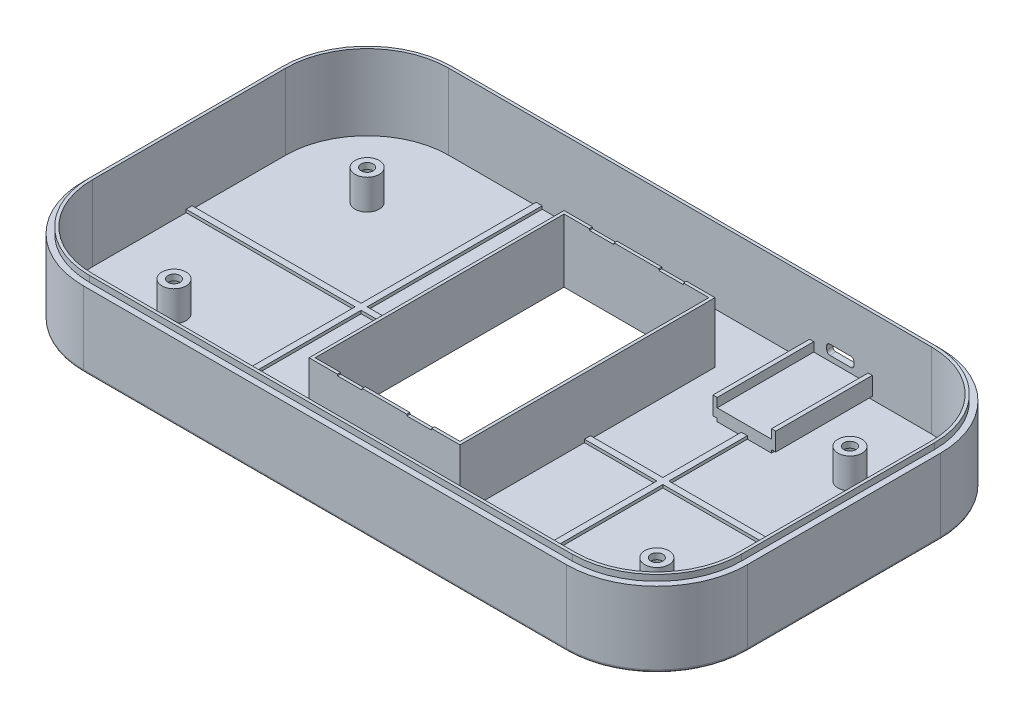
from build123d import *

# Parameters (mm, degrees)
BOSS_EXTRUDE1_DEPTH = 25
CUT_EXTRUDE1_DEPTH  = 23
BOSS_EXTRUDE2_DEPTH = 25
BOSS_EXTRUDE3_DEPTH = 2
SKETCH6_R           = 4
BOSS_EXTRUDE4_DEPTH = 10
SKETCH7_R           = 2
CUT_EXTRUDE2_DEPTH  = 54
SKETCH8_R           = 3.5
CUT_EXTRUDE3_DEPTH  = 10
BOSS_EXTRUDE5_DEPTH = 1
FILLET1_R           = 1
SKETCH11_W          = 25
SKETCH11_H          = 84.5
BOSS_EXTRUDE7_DEPTH = 22
CUT_EXTRUDE4_DEPTH  = 34.548411539
SKETCH13_W          = 8.2
SKETCH13_H          = 0.499092091
CUT_EXTRUDE5_DEPTH  = 94.548411539
SKETCH14_W          = 54
SKETCH14_H          = 88
SKETCH14_W_2        = 48
SKETCH14_H_2        = 82.5
CUT_EXTRUDE6_DEPTH  = 1
CUT_EXTRUDE7_DEPTH  = 2
SKETCH16_W          = 8
SKETCH16_H          = 6
CUT_EXTRUDE9_DEPTH  = 2
SKETCH17_W          = 18
SKETCH17_H          = 32
BOSS_EXTRUDE8_DEPTH = 4
SKETCH18_W          = 1.390332564
SKETCH18_H          = 32
BOSS_EXTRUDE9_DEPTH = 3
SKETCH19_W          = 9
SKETCH19_H          = 3.2
CUT_EXTRUDE10_DEPTH = 6
FILLET2_R           = 1
FILLET3_R           = 1
FILLET4_R           = 1
FILLET5_R           = 1
CUT_EXTRUDE12_DEPTH = 1


with BuildPart() as part:
    # Sketch1 → Boss-Extrude1 (new body)
    with BuildSketch(Plane(origin=(0, 0, 0), x_dir=(1, 0, 0), z_dir=(0, 1, 0))):
        with BuildLine():
            Line((-80, 62), (80, 62))
            ThreePointArc((80, 62), (101.213203436, 53.213203436), (110, 32))
            Line((110, 32), (110, -32))
            ThreePointArc((110, -32), (101.213203436, -53.213203436), (80, -62))
            Line((80, -62), (-80, -62))
            ThreePointArc((-80, -62), (-101.213203436, -53.213203436), (-110, -32))
            Line((-110, -32), (-110, 32))
            ThreePointArc((-110, 32), (-101.213203436, 53.213203436), (-80, 62))
        make_face()
    extrude(amount=BOSS_EXTRUDE1_DEPTH)

    # Sketch2 → Cut-Extrude1 (cut)
    with BuildSketch(Plane(origin=(0, 25, 0), x_dir=(1, 0, 0), z_dir=(0, 1, 0))):
        with BuildLine():
            Line((-80, -60), (80, -60))
            ThreePointArc((80, -60), (99.798989873, -51.798989873), (108, -32))
            Line((108, -32), (108, 32))
            ThreePointArc((108, 32), (99.798989873, 51.798989873), (80, 60))
            Line((80, 60), (-80, 60))
            ThreePointArc((-80, 60), (-99.798989873, 51.798989873), (-108, 32))
            Line((-108, 32), (-108, -32))
            ThreePointArc((-108, -32), (-99.798989873, -51.798989873), (-80, -60))
        make_face()
    extrude(amount=-CUT_EXTRUDE1_DEPTH, mode=Mode.SUBTRACT)

    # Sketch3 → Boss-Extrude2 (add)
    with BuildSketch(Plane(origin=(0, 2, 0), x_dir=(1, 0, 0), z_dir=(0, 1, 0))):
        with BuildLine():
            Line((-80, -60), (80, -60))
            ThreePointArc((80, -60), (99.798989873, -51.798989873), (108, -32))
            Line((108, -32), (108, 32))
            ThreePointArc((108, 32), (99.798989873, 51.798989873), (80, 60))
            Line((80, 60), (-80, 60))
            ThreePointArc((-80, 60), (-99.798989873, 51.798989873), (-108, 32))
            Line((-108, 32), (-108, -32))
            ThreePointArc((-108, -32), (-99.798989873, -51.798989873), (-80, -60))
        make_face()
        with BuildLine():
            Line((-80, -59), (80, -59))
            ThreePointArc((80, -59), (99.091883092, -51.091883092), (107, -32))
            Line((107, -32), (107, 32))
            ThreePointArc((107, 32), (99.091883092, 51.091883092), (80, 59))
            Line((80, 59), (-80, 59))
            ThreePointArc((-80, 59), (-99.091883092, 51.091883092), (-107, 32))
            Line((-107, 32), (-107, -32))
            ThreePointArc((-107, -32), (-99.091883092, -51.091883092), (-80, -59))
        make_face(mode=Mode.SUBTRACT)
    extrude(amount=BOSS_EXTRUDE2_DEPTH)

    # Sketch5 → Boss-Extrude3 (add)
    with BuildSketch(Plane.XZ):
        with BuildLine():
            Line((-88, 32), (-88, 20))
            Line((-88, 20), (-90, 20))
            Line((-90, 20), (-90, 32))
            ThreePointArc((-90, 32), (-87.071067812, 39.071067812), (-80, 42))
            Line((-80, 42), (-68, 42))
            Line((-68, 42), (-68, 40))
            Line((-68, 40), (-80, 40))
            ThreePointArc((-80, 40), (-85.656854249, 37.656854249), (-88, 32))
        make_face()
        with BuildLine():
            Line((-80, -40), (-68, -40))
            Line((-68, -40), (-68, -42))
            Line((-68, -42), (-80, -42))
            ThreePointArc((-80, -42), (-87.071067812, -39.071067812), (-90, -32))
            Line((-90, -32), (-90, -20))
            Line((-90, -20), (-88, -20))
            Line((-88, -20), (-88, -32))
            ThreePointArc((-88, -32), (-85.656854249, -37.656854249), (-80, -40))
        make_face()
        with BuildLine():
            Line((88, -32), (88, -20))
            Line((88, -20), (90, -20))
            Line((90, -20), (90, -32))
            ThreePointArc((90, -32), (87.071067812, -39.071067812), (80, -42))
            Line((80, -42), (68, -42))
            Line((68, -42), (68, -40))
            Line((68, -40), (80, -40))
            ThreePointArc((80, -40), (85.656854249, -37.656854249), (88, -32))
        make_face()
        with BuildLine():
            Line((80, 40), (68, 40))
            Line((68, 40), (68, 42))
            Line((68, 42), (80, 42))
            ThreePointArc((80, 42), (87.071067812, 39.071067812), (90, 32))
            Line((90, 32), (90, 20))
            Line((90, 20), (88, 20))
            Line((88, 20), (88, 32))
            ThreePointArc((88, 32), (85.656854249, 37.656854249), (80, 40))
        make_face()
    extrude(amount=BOSS_EXTRUDE3_DEPTH)

    # Sketch6 → Boss-Extrude4 (add)
    with BuildSketch(Plane(origin=(0, 2, 0), x_dir=(1, 0, 0), z_dir=(0, 1, 0))):
        with Locations((80, 32)):
            Circle(SKETCH6_R)
        with Locations((80, -32)):
            Circle(SKETCH6_R)
        with Locations((-80, -32)):
            Circle(SKETCH6_R)
        with Locations((-80, 32)):
            Circle(SKETCH6_R)
    extrude(amount=BOSS_EXTRUDE4_DEPTH)

    # Sketch7 → Cut-Extrude2 (cut)
    with BuildSketch(Plane(origin=(0, 12, 0), x_dir=(1, 0, 0), z_dir=(0, 1, 0))):
        with Locations((80, 32)):
            Circle(SKETCH7_R)
        with Locations((80, -32)):
            Circle(SKETCH7_R)
        with Locations((-80, -32)):
            Circle(SKETCH7_R)
        with Locations((-80, 32)):
            Circle(SKETCH7_R)
    extrude(amount=-CUT_EXTRUDE2_DEPTH, mode=Mode.SUBTRACT)

    # Sketch8 → Cut-Extrude3 (cut)
    with BuildSketch(Plane.XZ):
        with Locations((-80, 32)):
            Circle(SKETCH8_R)
        with Locations((-80, -32)):
            Circle(SKETCH8_R)
        with Locations((80, -32)):
            Circle(SKETCH8_R)
        with Locations((80, 32)):
            Circle(SKETCH8_R)
    extrude(amount=-CUT_EXTRUDE3_DEPTH, mode=Mode.SUBTRACT)

    # Sketch9 → Boss-Extrude5 (add)
    with BuildSketch(Plane(origin=(0, 2, 0), x_dir=(1, 0, 0), z_dir=(0, 1, 0))):
        Polygon((49, -59), (51, -59), (51, -1), (107, -1), (107, 1), (51, 1), (51, 59), (49, 59), (49, 1), (1, 1), (1, 59), (-1, 59), (-1, 1), (-49, 1), (-49, 59), (-51, 59), (-51, 1), (-107, 1), (-107, -1), (-51, -1), (-51, -59), (-49, -59), (-49, -1), (-1, -1), (-1, -59), (1, -59), (1, -1), (49, -1), align=None)
    extrude(amount=BOSS_EXTRUDE5_DEPTH)

    # Fillet1
    fillet1_edges = [part.edges().sort_by_distance(p)[0] for p in [
        (0, 0, 62),
        (-101.213203436, 0, 53.213203436),
        (-110, 0, 0),
        (-101.213203436, 0, -53.213203436),
        (0, 0, -62),
        (101.213203436, 0, -53.213203436),
        (110, 0, 0),
        (101.213203436, 0, 53.213203436),
    ]]
    fillet(fillet1_edges, radius=FILLET1_R)

    # Sketch11 → Boss-Extrude7 (add)
    with BuildSketch(Plane.XZ):
        with Locations((12.5, 0)):
            Rectangle(SKETCH11_W, SKETCH11_H)
        with Locations((-12.5, 0)):
            Rectangle(SKETCH11_W, SKETCH11_H)
    extrude(amount=-BOSS_EXTRUDE7_DEPTH)

    # Sketch12 → Cut-Extrude4 (cut)
    with BuildSketch(Plane(origin=(0, 22, 0), x_dir=(1, 0, 0), z_dir=(0, 1, 0))):
        Polygon((-24, 41.25), (-24, 40.56), (24, -40.56), (24, 41.25), align=None)
        Polygon((24, -40.56), (-24, 40.56), (-24, -41.25), (24, -41.25), align=None)
    extrude(amount=-CUT_EXTRUDE4_DEPTH, mode=Mode.SUBTRACT)

    # Sketch13 → Cut-Extrude5 (cut)
    with BuildSketch(Plane.XY.offset(42.25)):
        with Locations((11.5, 21.750453955)):
            Rectangle(SKETCH13_W, SKETCH13_H)
        with Locations((-11.5, 21.750453955)):
            Rectangle(SKETCH13_W, SKETCH13_H)
    extrude(amount=-CUT_EXTRUDE5_DEPTH, mode=Mode.SUBTRACT)

    # Sketch14 → Cut-Extrude6 (cut)
    with BuildSketch(Plane.XZ):
        Rectangle(SKETCH14_W, SKETCH14_H)
        Rectangle(SKETCH14_W_2, SKETCH14_H_2, mode=Mode.SUBTRACT)
    extrude(amount=-CUT_EXTRUDE6_DEPTH, mode=Mode.SUBTRACT)

    # Sketch15 → Cut-Extrude7 (cut)
    with BuildSketch(Plane.XZ.offset(-1)):
        Polygon((-4, -42.655755812), (-4, -44), (4, -44), (4, -42.655755812), (0, -42.625), align=None)
    extrude(amount=-CUT_EXTRUDE7_DEPTH, mode=Mode.SUBTRACT)

    # Sketch16 → Cut-Extrude9 (cut)
    with BuildSketch(Plane(origin=(0, 3, 0), x_dir=(1, 0, 0), z_dir=(0, 1, 0))):
        with Locations((0, 47)):
            Rectangle(SKETCH16_W, SKETCH16_H)
    extrude(amount=-CUT_EXTRUDE9_DEPTH, mode=Mode.SUBTRACT)

    # Sketch17 → Boss-Extrude8 (add)
    with BuildSketch(Plane(origin=(0, 2, 0), x_dir=(1, 0, 0), z_dir=(0, 1, 0))):
        with Locations((50, 43)):
            Rectangle(SKETCH17_W, SKETCH17_H)
    extrude(amount=BOSS_EXTRUDE8_DEPTH)

    # Sketch18 → Boss-Extrude9 (add, symmetric)
    with BuildSketch(Plane(origin=(0, 6, 0), x_dir=(1, 0, 0), z_dir=(0, 1, 0))):
        with Locations((40.304833718, 43)):
            Rectangle(SKETCH18_W, SKETCH18_H)
        with Locations((59.695166282, 43)):
            Rectangle(SKETCH18_W, SKETCH18_H)
    extrude(amount=BOSS_EXTRUDE9_DEPTH, both=True)

    # Sketch19 → Cut-Extrude10 (cut)
    with BuildSketch(Plane.XY.offset(-59)):
        with Locations((49.8, 9.35)):
            Rectangle(SKETCH19_W, SKETCH19_H)
    extrude(amount=-CUT_EXTRUDE10_DEPTH, mode=Mode.SUBTRACT)

    # Fillet2
    fillet2_edges = [part.edges().sort_by_distance(p)[0] for p in [
        (54.3, 7.75, -60.5),
    ]]
    fillet(fillet2_edges, radius=FILLET2_R)

    # Fillet3
    fillet3_edges = [part.edges().sort_by_distance(p)[0] for p in [
        (45.3, 7.75, -60.5),
    ]]
    fillet(fillet3_edges, radius=FILLET3_R)

    # Fillet4
    fillet4_edges = [part.edges().sort_by_distance(p)[0] for p in [
        (45.3, 10.95, -60.5),
    ]]
    fillet(fillet4_edges, radius=FILLET4_R)

    # Fillet5
    fillet5_edges = [part.edges().sort_by_distance(p)[0] for p in [
        (54.3, 10.95, -60.5),
    ]]
    fillet(fillet5_edges, radius=FILLET5_R)

    # Sketch20 → Cut-Extrude12 (cut)
    with BuildSketch(Plane(origin=(0, 0, -62), x_dir=(-1, 0, 0), z_dir=(0, 0, -1))):
        with BuildLine():
            Line((-56.249828927, 12.40837238), (-43.350171073, 12.40837238))
            ThreePointArc((-43.350171073, 12.40837238), (-42.289510901, 11.969032552), (-41.850171073, 10.90837238))
            Line((-41.850171073, 10.90837238), (-41.850171073, 7.79162762))
            ThreePointArc((-41.850171073, 7.79162762), (-42.289510901, 6.730967448), (-43.350171073, 6.29162762))
            Line((-43.350171073, 6.29162762), (-56.249828927, 6.29162762))
            ThreePointArc((-56.249828927, 6.29162762), (-57.310489099, 6.730967448), (-57.749828927, 7.79162762))
            Line((-57.749828927, 7.79162762), (-57.749828927, 10.90837238))
            ThreePointArc((-57.749828927, 10.90837238), (-57.310489099, 11.969032552), (-56.249828927, 12.40837238))
        make_face()
    extrude(amount=-CUT_EXTRUDE12_DEPTH, mode=Mode.SUBTRACT)


solid = part.part
